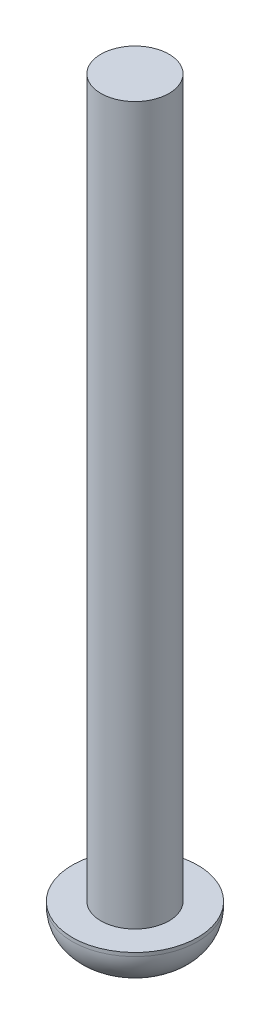
from build123d import *

# Parameters (mm, degrees)
SKETCH1_R           = 3.5
BOSS_EXTRUDE1_DEPTH = 2.2
SKETCH2_R           = 1.9
BOSS_EXTRUDE2_DEPTH = 40
FILLET1_R           = 2


with BuildPart() as part:
    # Sketch1 → Boss-Extrude1 (new body)
    with BuildSketch(Plane(origin=(0, 0, 0), x_dir=(1, 0, 0), z_dir=(0, 1, 0))):
        Circle(SKETCH1_R)
    extrude(amount=BOSS_EXTRUDE1_DEPTH)

    # Sketch2 → Boss-Extrude2 (add)
    with BuildSketch(Plane(origin=(0, 2.2, 0), x_dir=(1, 0, 0), z_dir=(0, 1, 0))):
        Circle(SKETCH2_R)
    extrude(amount=BOSS_EXTRUDE2_DEPTH)

    # Fillet1
    fillet1_edges = [part.edges().sort_by_distance(p)[0] for p in [
        (-3.5, 0, 0),
    ]]
    fillet(fillet1_edges, radius=FILLET1_R)


solid = part.part
